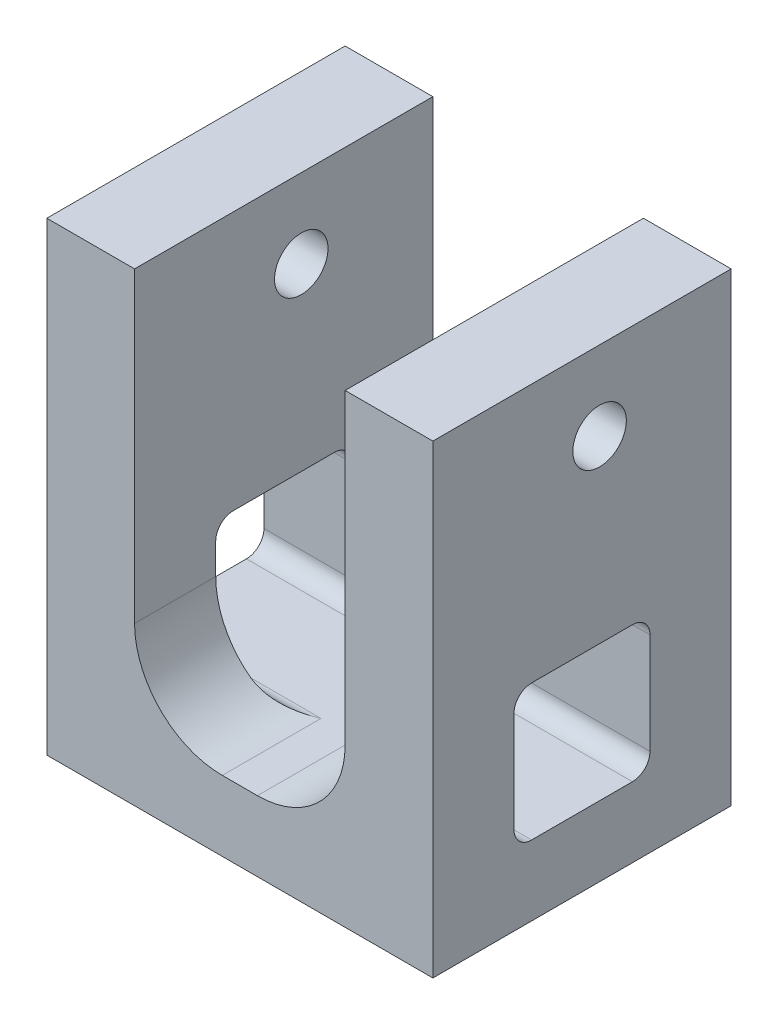
from build123d import *
from OCP.BRepFilletAPI import BRepFilletAPI_MakeFillet

# Parameters (mm, degrees)
EXTRUDE_1_DEPTH     = 34
SKETCH_2_R          = 2.6
CUT_EXTRUDE_1_DEPTH = 30
SKETCH_3_R          = 3.05
CUT_EXTRUDE_2_DEPTH = 50
SKETCH_8_W          = 15.5
SKETCH_8_H          = 15.5
CUT_EXTRUDE_5_DEPTH = 50
FILLET_4_R1         = 2
FILLET_4_R2         = 10


with BuildPart() as part:
    # 草图1 → 凸台-拉伸1 (new body)
    with BuildSketch(Plane.XY):
        Polygon((-22, 45.701761355), (-12, 45.701761355), (-12, 0.701761355), (12, 0.701761355), (12, 45.701761355), (22, 45.701761355), (22, -7.298238645), (-22, -7.298238645), align=None)
    extrude(amount=EXTRUDE_1_DEPTH)

    # 草图2 → 切除-拉伸1 (cut, symmetric)
    with BuildSketch(Plane(origin=(0, 0, 0), x_dir=(1, 0, 0), z_dir=(0, 1, 0))):
        with Locations((0, -17)):
            Circle(SKETCH_2_R)
    extrude(amount=CUT_EXTRUDE_1_DEPTH, both=True, mode=Mode.SUBTRACT)

    # 草图3 → 切除-拉伸2 (cut)
    with BuildSketch(Plane.ZY.offset(22)):
        with Locations((15, 36.701761355)):
            Circle(SKETCH_3_R)
    extrude(amount=-CUT_EXTRUDE_2_DEPTH, mode=Mode.SUBTRACT)

    # 草图8 → 切除-拉伸5 (cut)
    with BuildSketch(Plane.ZY.offset(22)):
        with Locations((17, 8.451761355)):
            Rectangle(SKETCH_8_W, SKETCH_8_H)
    extrude(amount=-CUT_EXTRUDE_5_DEPTH, mode=Mode.SUBTRACT)

    # 圆角4: one fillet with a radius per group of edges: ONE call of the kernel's fillet builder (fillet() takes one radius for all edges)
    fillet_4_edges_1 = [part.edges().sort_by_distance(p)[0] for p in [
        (-17, 16.201761355, 9.25),
        (-17, 16.201761355, 24.75),
        (-17, 0.701761355, 24.75),
        (-17, 0.701761355, 9.25),
        (17, 0.701761355, 9.25),
        (17, 16.201761355, 9.25),
        (17, 0.701761355, 24.75),
        (17, 16.201761355, 24.75),
    ]]
    fillet_4_edges_2 = [part.edges().sort_by_distance(p)[0] for p in [
        (-12, 0.701761355, 4.625),
        (-12, 0.701761355, 29.375),
        (12, 0.701761355, 29.375),
        (12, 0.701761355, 4.625),
    ]]
    fillet_4 = BRepFilletAPI_MakeFillet(part.part.solid().wrapped)
    for e in fillet_4_edges_1:
        fillet_4.Add(FILLET_4_R1, e.wrapped)
    for e in fillet_4_edges_2:
        fillet_4.Add(FILLET_4_R2, e.wrapped)
    add(Compound.cast(fillet_4.Shape()), mode=Mode.REPLACE)


solid = part.part
